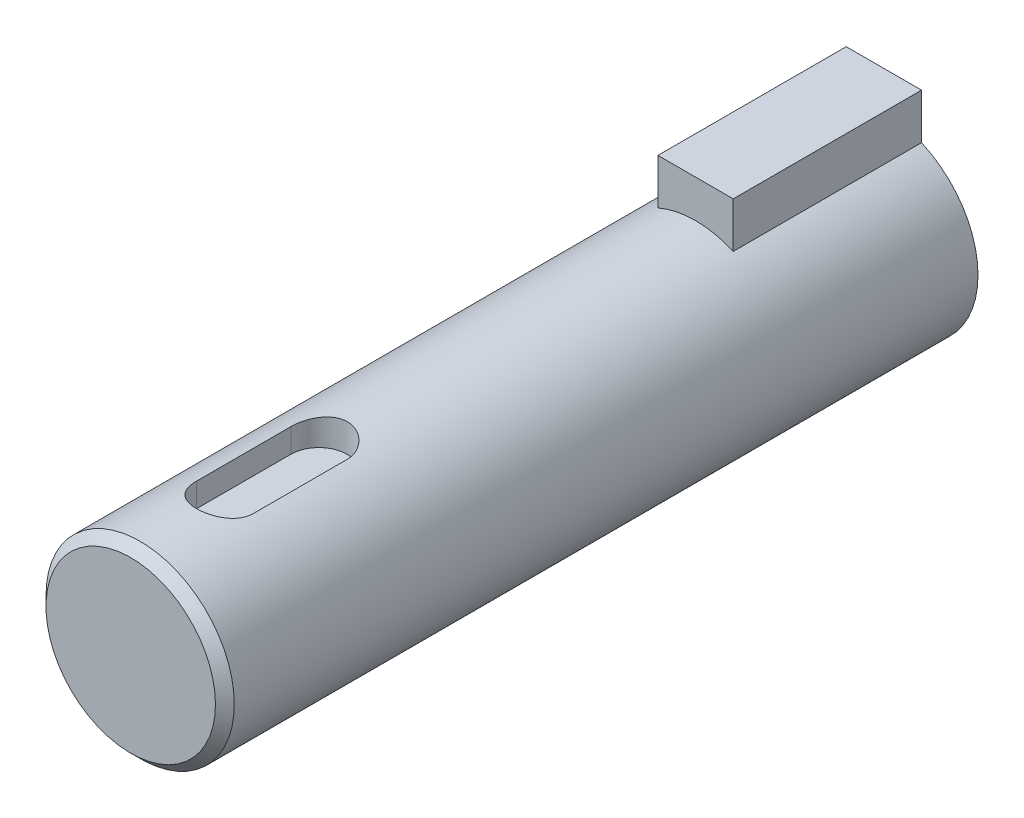
from build123d import *

# Parameters (mm, degrees)
BOSS_EXTRUDE1_DEPTH = 10
SKETCH2_R           = 5
BOSS_EXTRUDE2_DEPTH = 30
CUT_EXTRUDE1_START  = 3.5
CUT_EXTRUDE1_DEPTH  = 4.5
CHAMFER1_SIZE       = 0.5


with BuildPart() as part:
    # Sketch1 → Boss-Extrude1 (new body)
    with BuildSketch(Plane.XY):
        with BuildLine():
            Line((-2, 7), (2, 7))
            Line((2, 7), (2, 4.582575695))
            ThreePointArc((2, 4.582575695), (0, -5), (-2, 4.582575695))
            Line((-2, 4.582575695), (-2, 7))
        make_face()
    extrude(amount=BOSS_EXTRUDE1_DEPTH)

    # Sketch2 → Boss-Extrude2 (add)
    with BuildSketch(Plane.XY.offset(10)):
        Circle(SKETCH2_R)
    extrude(amount=BOSS_EXTRUDE2_DEPTH)

    # Sketch3 → Cut-Extrude1 (cut, through all)
    with BuildSketch(Plane(origin=(0, 0, 0), x_dir=(1, 0, 0), z_dir=(0, 1, 0)).offset(CUT_EXTRUDE1_START)):
        with BuildLine():
            Line((-1.5, -35), (-1.5, -30))
            ThreePointArc((-1.5, -30), (0, -28.5), (1.5, -30))
            Line((1.5, -30), (1.5, -35))
            ThreePointArc((1.5, -35), (0, -36.5), (-1.5, -35))
        make_face()
    extrude(amount=CUT_EXTRUDE1_DEPTH, mode=Mode.SUBTRACT)

    # Chamfer1
    chamfer1_edges = [part.edges().sort_by_distance(p)[0] for p in [
        (-5, 0, 40),
    ]]
    chamfer(chamfer1_edges, length=CHAMFER1_SIZE)


solid = part.part
